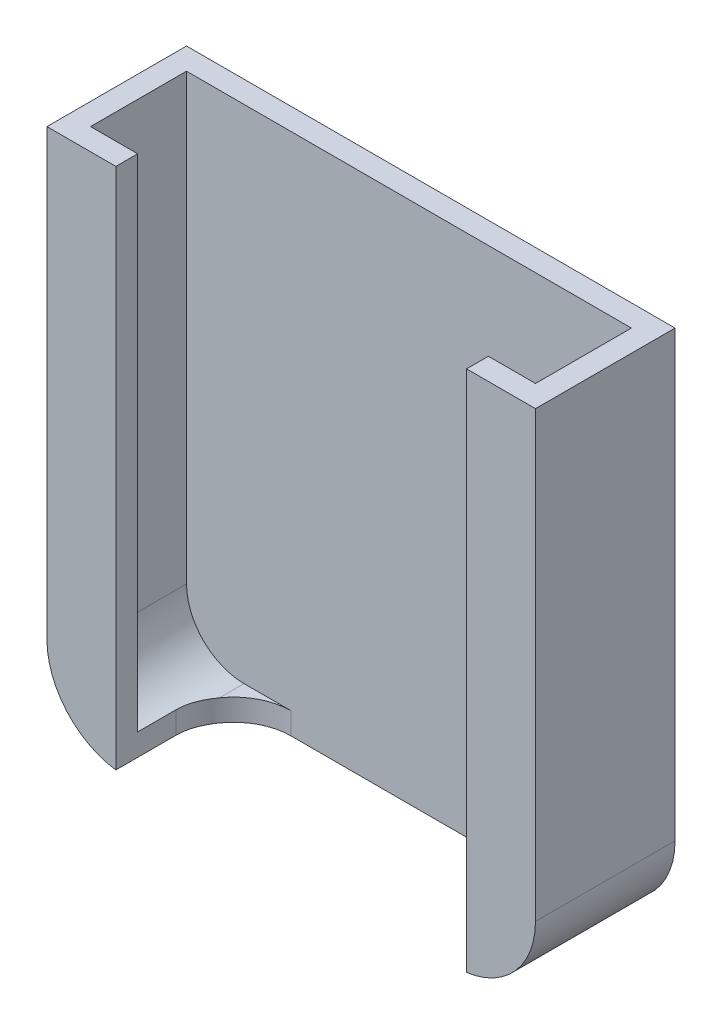
from build123d import *

# Parameters (mm, degrees)
SKETCH1_W           = 71.12
SKETCH1_H           = 76.2
BOSS_EXTRUDE1_DEPTH = 10.16
SKETCH2_W           = 64.77
SKETCH2_H           = 13.97
CUT_EXTRUDE1_DEPTH  = 73.025
SKETCH10_W          = 51.054
SKETCH10_H          = 17.145
CUT_EXTRUDE2_DEPTH  = 77.2
FILLET5_R           = 8.382
FILLET3_R           = 8.382
CUT_EXTRUDE3_DEPTH  = 21.32


with BuildPart() as part:
    # Sketch1 → Boss-Extrude1 (new body, symmetric)
    with BuildSketch(Plane.XY):
        with Locations((35.56, 38.1)):
            Rectangle(SKETCH1_W, SKETCH1_H)
    extrude(amount=BOSS_EXTRUDE1_DEPTH, both=True)

    # Sketch2 → Cut-Extrude1 (cut)
    with BuildSketch(Plane(origin=(0, 76.2, 0), x_dir=(1, 0, 0), z_dir=(0, 1, 0))):
        with Locations((35.56, 0)):
            Rectangle(SKETCH2_W, SKETCH2_H)
    extrude(amount=-CUT_EXTRUDE1_DEPTH, mode=Mode.SUBTRACT)

    # Sketch10 → Cut-Extrude2 (cut, through all)
    with BuildSketch(Plane(origin=(0, 76.2, 0), x_dir=(1, 0, 0), z_dir=(0, 1, 0))):
        with Locations((35.56, -1.5875)):
            Rectangle(SKETCH10_W, SKETCH10_H)
    extrude(amount=-CUT_EXTRUDE2_DEPTH, mode=Mode.SUBTRACT)

    # Fillet5
    fillet5_edges = [part.edges().sort_by_distance(p)[0] for p in [
        (61.087, 1.5875, -6.985),
        (10.033, 1.5875, -6.985),
    ]]
    fillet(fillet5_edges, radius=FILLET5_R)

    # Fillet3
    fillet3_edges = [part.edges().sort_by_distance(p)[0] for p in [
        (67.945, 3.175, 0),
        (3.175, 3.175, 0),
    ]]
    fillet(fillet3_edges, radius=FILLET3_R)

    # Sketch11 → Cut-Extrude3 (cut, through all)
    with BuildSketch(Plane.XY.offset(10.16)):
        with BuildLine():
            Line((0, 11.557), (0, 0))
            Line((0, 0), (11.557, 0))
            ThreePointArc((11.557, 0), (3.38496693, 3.38496693), (0, 11.557))
        make_face()
        with BuildLine():
            Line((71.12, 11.557), (71.12, 0))
            Line((71.12, 0), (59.563, 0))
            ThreePointArc((59.563, 0), (67.73503307, 3.38496693), (71.12, 11.557))
        make_face()
    extrude(amount=-CUT_EXTRUDE3_DEPTH, mode=Mode.SUBTRACT)


solid = part.part
